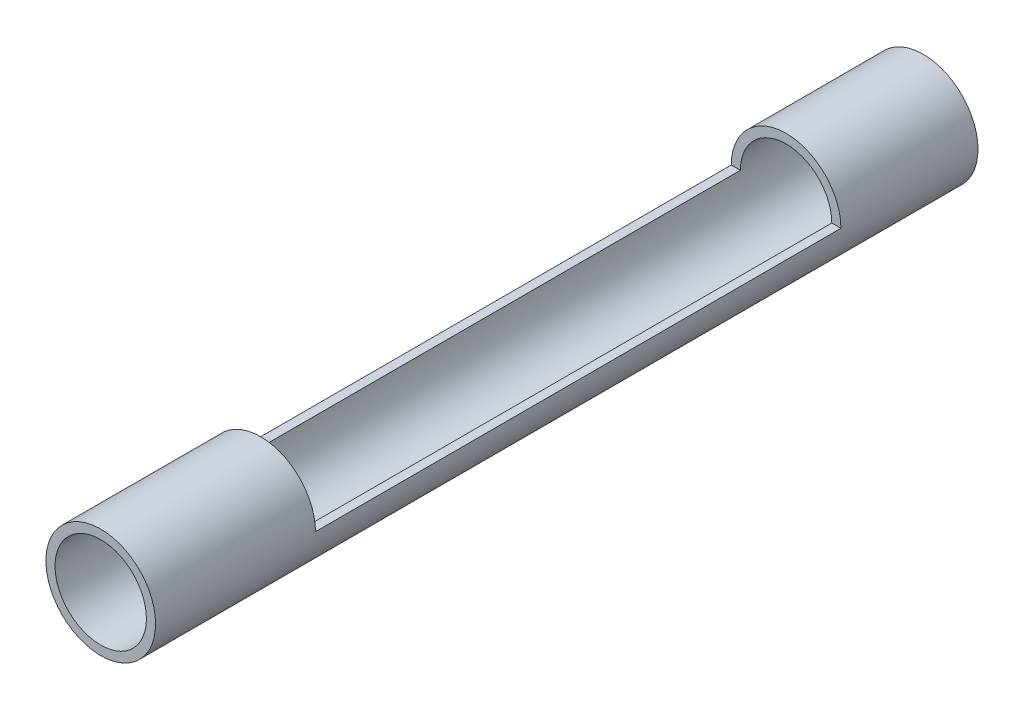
from build123d import *

# Parameters (mm, degrees)
SCHIZZO1_R                    = 12
SCHIZZO1_R_2                  = 10
ESTRUSIONE_ESTRUSIONE1_DEPTH  = 180
TAGLIO_ESTRUSIONE1_DEPTH      = 20
TAGLIO_ESTRUSIONE1_DEPTH_BACK = 20
SCHIZZO2_W                    = 115
SCHIZZO2_H                    = 12


with BuildPart() as part:
    # Schizzo1 → Estrusione-Estrusione1 (new body)
    with BuildSketch(Plane.XY):
        Circle(SCHIZZO1_R)
        Circle(SCHIZZO1_R_2, mode=Mode.SUBTRACT)
    extrude(amount=ESTRUSIONE_ESTRUSIONE1_DEPTH)

    # Schizzo2 → Taglio-Estrusione1 (cut, two sides: drawn at the far end of the back side and taken through both)
    with BuildSketch(Plane(origin=(0, 0, 0), x_dir=(0, 0, -1), z_dir=(1, 0, 0)).offset(-TAGLIO_ESTRUSIONE1_DEPTH_BACK)):
        with Locations((-87.5, 6)):
            Rectangle(SCHIZZO2_W, SCHIZZO2_H)
    extrude(amount=TAGLIO_ESTRUSIONE1_DEPTH + TAGLIO_ESTRUSIONE1_DEPTH_BACK, mode=Mode.SUBTRACT)


solid = part.part
